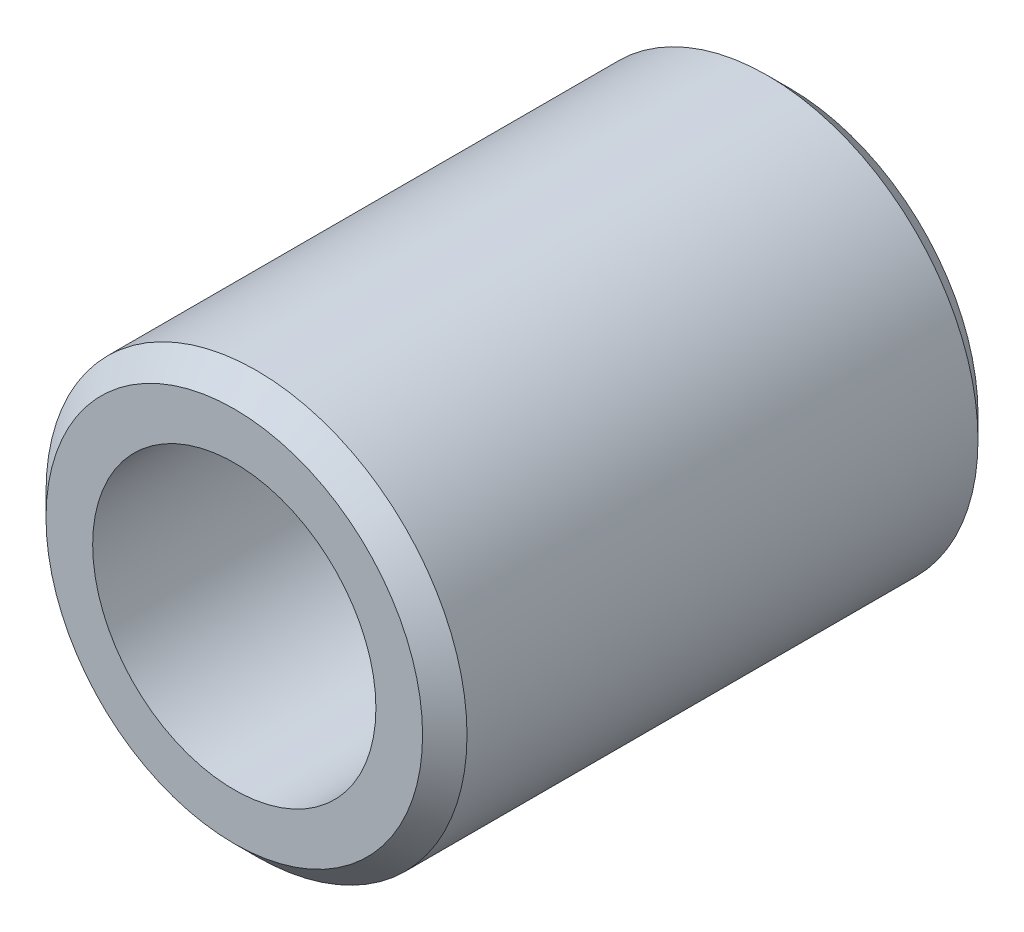
from build123d import *


with BuildPart() as part:
    # Sketch1 → Revolve1 (revolve)
    with BuildSketch(Plane(origin=(0, 0, 0), x_dir=(0, 0, -1), z_dir=(1, 0, 0))):
        Polygon((-3.175, 2.15265), (-3.175, 1.61925), (3.175, 1.61925), (3.175, 2.15265), (2.921, 2.40665), (-2.921, 2.40665), align=None)
    revolve(axis=Axis((0, 0, -3.175), (0, 0, 1)))


solid = part.part
